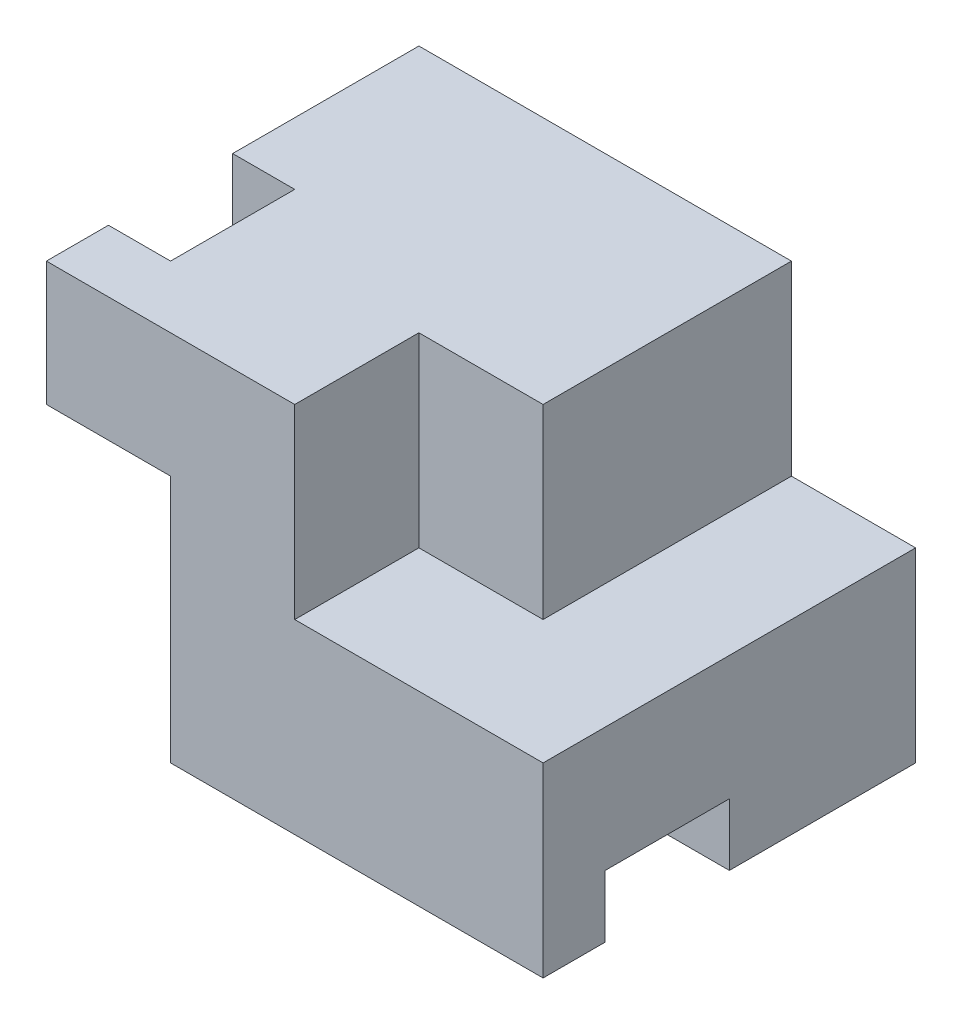
from build123d import *

# Parameters (mm, degrees)
SKETCH2_W           = 203.2
SKETCH2_H           = 152.4
BOSS_EXTRUDE1_DEPTH = 152.4
SKETCH4_W           = 50.8
SKETCH4_H           = 101.6
CUT_EXTRUDE1_DEPTH  = 76.2
SKETCH5_W           = 25.4
SKETCH5_H           = 50.8
CUT_EXTRUDE2_DEPTH  = 76.2
SKETCH6_W           = 50.8
SKETCH6_H           = 25.4
CUT_EXTRUDE3_DEPTH  = 152.4
CUT_EXTRUDE4_DEPTH  = 76.2


with BuildPart() as part:
    # Sketch2 → Boss-Extrude1 (new body)
    with BuildSketch(Plane.XY):
        with Locations((101.6, 76.2)):
            Rectangle(SKETCH2_W, SKETCH2_H)
    extrude(amount=-BOSS_EXTRUDE1_DEPTH)

    # Sketch4 → Cut-Extrude1 (cut)
    with BuildSketch(Plane.XY):
        with Locations((25.4, 50.8)):
            Rectangle(SKETCH4_W, SKETCH4_H)
    extrude(amount=-CUT_EXTRUDE1_DEPTH, mode=Mode.SUBTRACT)

    # Sketch5 → Cut-Extrude2 (cut)
    with BuildSketch(Plane(origin=(0, 152.4, 0), x_dir=(1, 0, 0), z_dir=(0, 1, 0))):
        with Locations((12.7, 50.8)):
            Rectangle(SKETCH5_W, SKETCH5_H)
    extrude(amount=-CUT_EXTRUDE2_DEPTH, mode=Mode.SUBTRACT)

    # Sketch6 → Cut-Extrude3 (cut)
    with BuildSketch(Plane(origin=(203.2, 0, 0), x_dir=(0, 0, -1), z_dir=(1, 0, 0))):
        with Locations((50.8, 12.7)):
            Rectangle(SKETCH6_W, SKETCH6_H)
    extrude(amount=-CUT_EXTRUDE3_DEPTH, mode=Mode.SUBTRACT)

    # Sketch7 → Cut-Extrude4 (cut)
    with BuildSketch(Plane(origin=(0, 152.4, 0), x_dir=(1, 0, 0), z_dir=(0, 1, 0))):
        Polygon((152.4, 152.4), (152.4, 50.8), (101.6, 50.8), (101.6, 0), (203.2, 0), (203.2, 152.4), align=None)
    extrude(amount=-CUT_EXTRUDE4_DEPTH, mode=Mode.SUBTRACT)


solid = part.part
